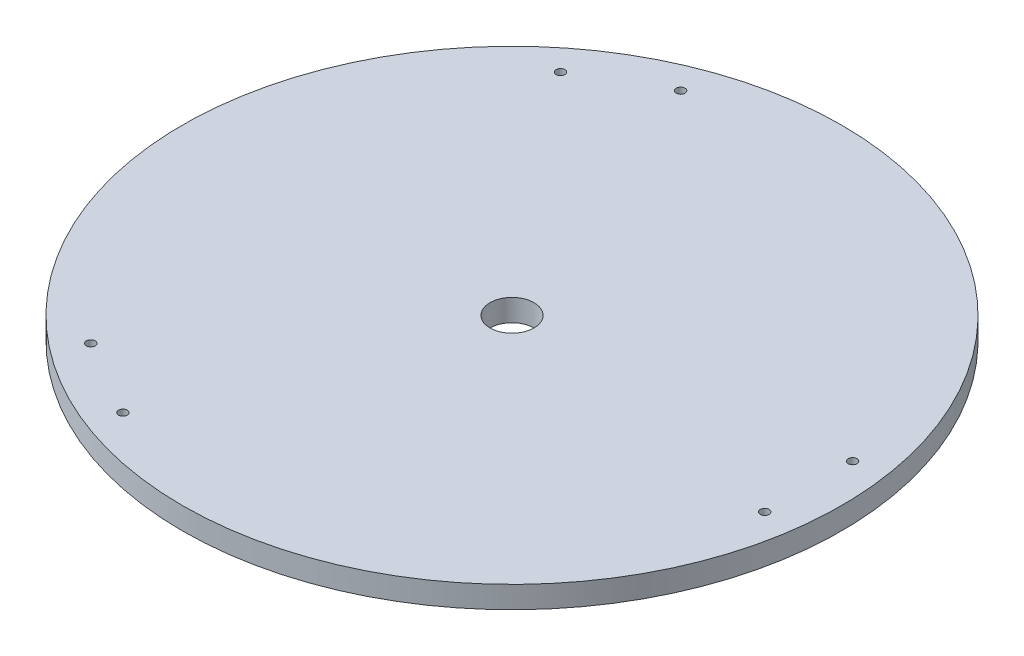
from build123d import *

# Parameters (mm, degrees)
SKETCH1_R           = 150
SKETCH1_R_2         = 10
SKETCH1_R_3         = 2
BOSS_EXTRUDE1_DEPTH = 10


with BuildPart() as part:
    # Sketch1 → Boss-Extrude1 (new body)
    with BuildSketch(Plane(origin=(0, 0, 0), x_dir=(1, 0, 0), z_dir=(0, 1, 0))):
        Circle(SKETCH1_R)
        Circle(SKETCH1_R_2, mode=Mode.SUBTRACT)
        with Locations((135, 20)):
            Circle(SKETCH1_R_3, mode=Mode.SUBTRACT)
        with Locations((135, -20)):
            Circle(SKETCH1_R_3, mode=Mode.SUBTRACT)
        with Locations((-50.179491924, -126.913429511)):
            Circle(SKETCH1_R_3, mode=Mode.SUBTRACT)
        with Locations((-84.820508076, -106.913429511)):
            Circle(SKETCH1_R_3, mode=Mode.SUBTRACT)
        with Locations((-84.820508076, 106.913429511)):
            Circle(SKETCH1_R_3, mode=Mode.SUBTRACT)
        with Locations((-50.179491924, 126.913429511)):
            Circle(SKETCH1_R_3, mode=Mode.SUBTRACT)
    extrude(amount=BOSS_EXTRUDE1_DEPTH)


solid = part.part
